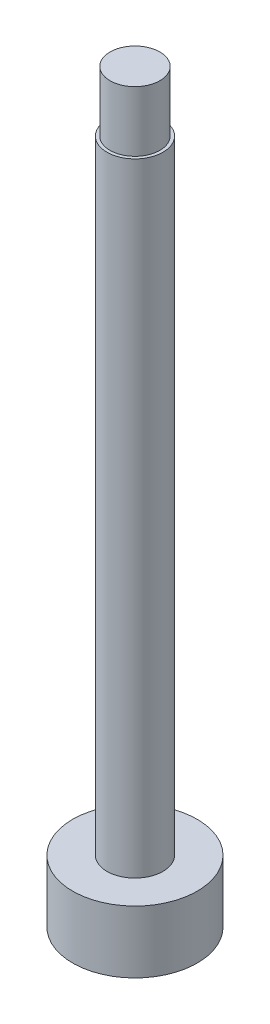
from build123d import *


with BuildPart() as part:
    # Sketch1 → Revolve1 (revolve)
    with BuildSketch(Plane.XY):
        Polygon((0, 0), (0, 20), (-0.1, 20), (-0.1, 21.938325991), (-0.9, 21.938325991), (-0.9, -2), (1.1, -2), (1.1, 0), align=None)
    revolve(axis=Axis((-0.9, 21.938325991, 0), (0, -1, 0)))


solid = part.part
